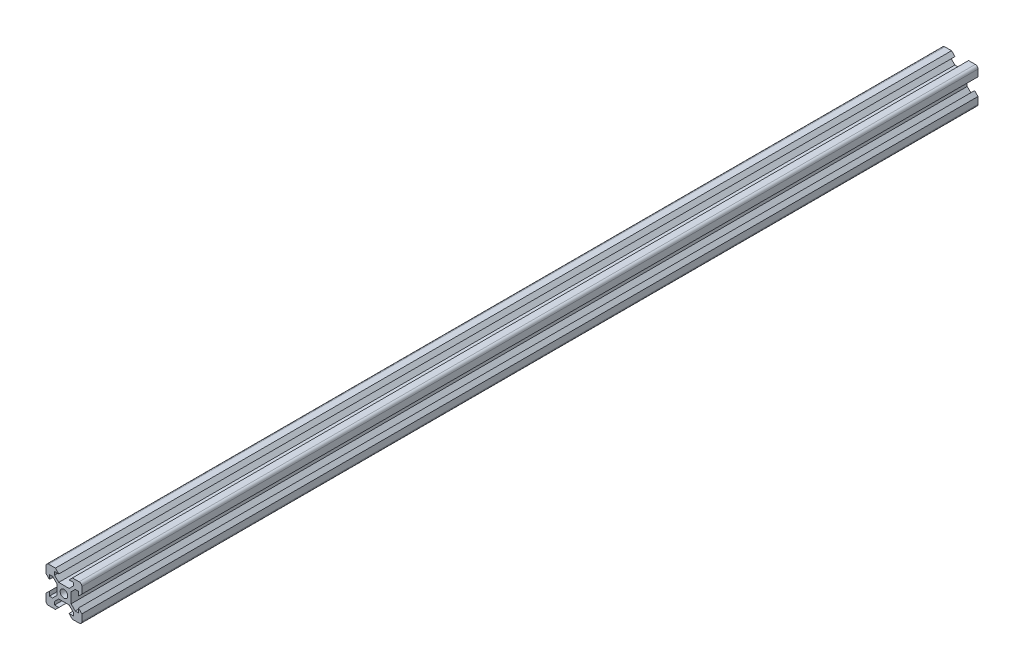
from build123d import *

# Parameters (mm, degrees)
SKETCH1_R           = 2.125
BOSS_EXTRUDE1_DEPTH = 500


with BuildPart() as part:
    # Sketch1 → Boss-Extrude1 (new body)
    with BuildSketch(Plane.XY):
        with BuildLine():
            Line((8.1, 5.225), (8.1, 2.85))
            Line((8.1, 2.85), (10, 4.75))
            Line((10, 4.75), (10, 8.5))
            ThreePointArc((10, 8.5), (9.560660172, 9.560660172), (8.5, 10))
            Line((8.5, 10), (4.75, 10))
            Line((4.75, 10), (2.85, 8.1))
            Line((2.85, 8.1), (5.225, 8.1))
            Line((5.225, 8.1), (5.225, 6.325))
            Line((5.225, 6.325), (2.9, 4))
            Line((2.9, 4), (-2.9, 4))
            Line((-2.9, 4), (-5.225, 6.325))
            Line((-5.225, 6.325), (-5.225, 8.1))
            Line((-5.225, 8.1), (-2.85, 8.1))
            Line((-2.85, 8.1), (-4.75, 10))
            Line((-4.75, 10), (-8.5, 10))
            ThreePointArc((-8.5, 10), (-9.560660172, 9.560660172), (-10, 8.5))
            Line((-10, 8.5), (-10, 4.75))
            Line((-10, 4.75), (-8.1, 2.85))
            Line((-8.1, 2.85), (-8.1, 5.225))
            Line((-8.1, 5.225), (-6.325, 5.225))
            Line((-6.325, 5.225), (-4, 2.9))
            Line((-4, 2.9), (-4, -2.9))
            Line((-4, -2.9), (-6.325, -5.225))
            Line((-6.325, -5.225), (-8.1, -5.225))
            Line((-8.1, -5.225), (-8.1, -2.85))
            Line((-8.1, -2.85), (-10, -4.75))
            Line((-10, -4.75), (-10, -8.5))
            ThreePointArc((-10, -8.5), (-9.560660172, -9.560660172), (-8.5, -10))
            Line((-8.5, -10), (-4.75, -10))
            Line((-4.75, -10), (-2.85, -8.1))
            Line((-2.85, -8.1), (-5.225, -8.1))
            Line((-5.225, -8.1), (-5.225, -6.325))
            Line((-5.225, -6.325), (-2.9, -4))
            Line((-2.9, -4), (2.9, -4))
            Line((2.9, -4), (5.225, -6.325))
            Line((5.225, -6.325), (5.225, -8.1))
            Line((5.225, -8.1), (2.85, -8.1))
            Line((2.85, -8.1), (4.75, -10))
            Line((4.75, -10), (8.5, -10))
            ThreePointArc((8.5, -10), (9.560660172, -9.560660172), (10, -8.5))
            Line((10, -8.5), (10, -4.75))
            Line((10, -4.75), (8.1, -2.85))
            Line((8.1, -2.85), (8.1, -5.225))
            Line((8.1, -5.225), (6.325, -5.225))
            Line((6.325, -5.225), (4, -2.9))
            Line((4, -2.9), (4, 2.9))
            Line((4, 2.9), (6.325, 5.225))
            Line((6.325, 5.225), (8.1, 5.225))
        make_face()
        Circle(SKETCH1_R, mode=Mode.SUBTRACT)
    extrude(amount=BOSS_EXTRUDE1_DEPTH)


solid = part.part
